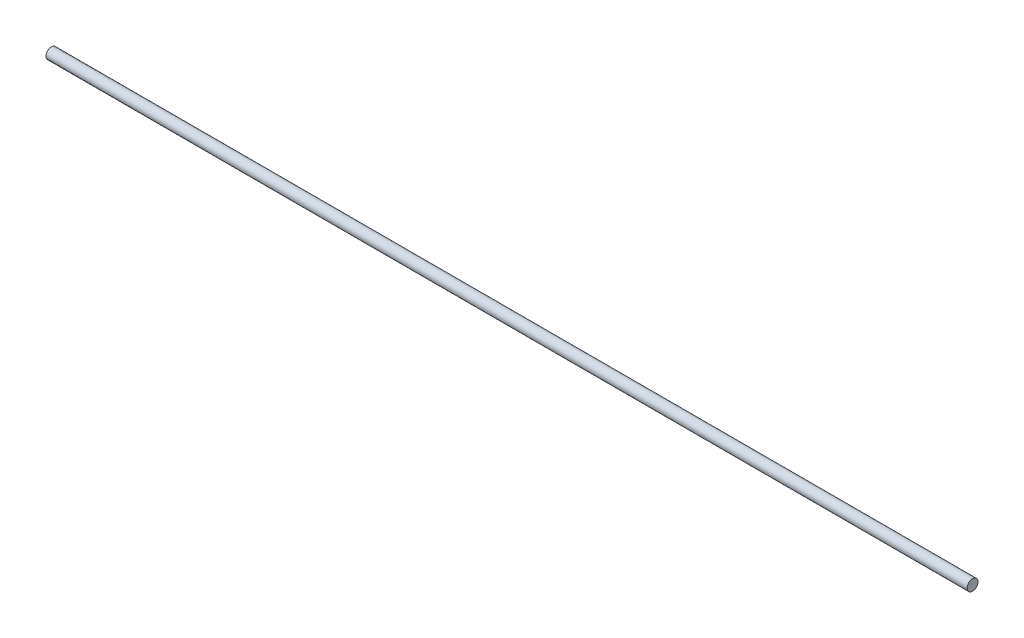
from build123d import *

# Parameters (mm, degrees)
SKETCH1_R           = 2
BOSS_EXTRUDE1_DEPTH = 340


with BuildPart() as part:
    # Sketch1 → Boss-Extrude1 (new body)
    with BuildSketch(Plane(origin=(0, 0, 0), x_dir=(0, 0, -1), z_dir=(1, 0, 0))):
        Circle(SKETCH1_R)
    extrude(amount=BOSS_EXTRUDE1_DEPTH)


solid = part.part
